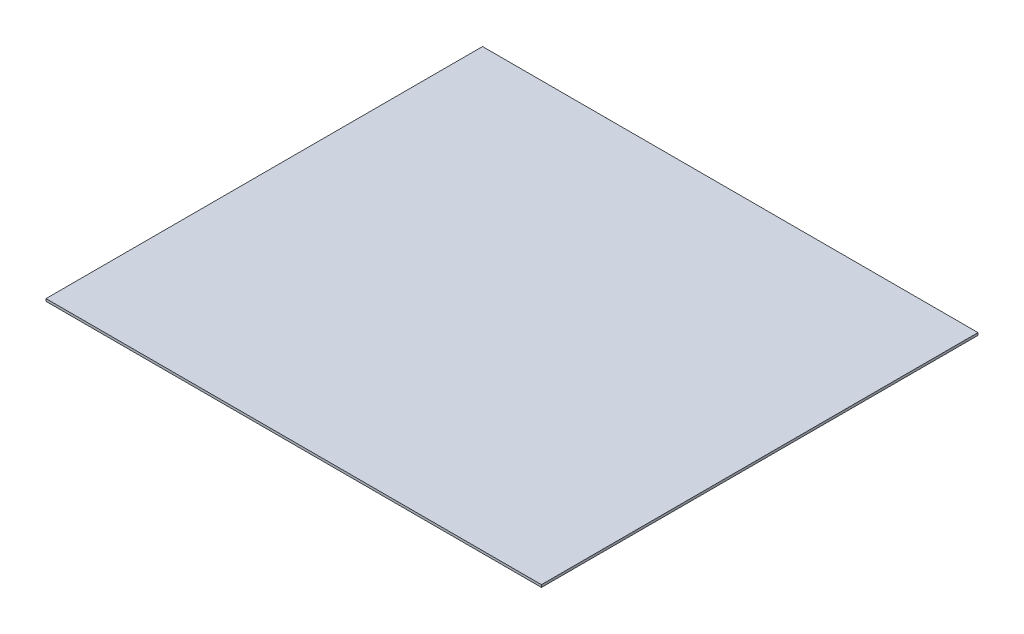
from build123d import *

# Parameters (mm, degrees)
SKETCH1_W           = 2565.4
SKETCH1_H           = 2260.346
BOSS_EXTRUDE1_DEPTH = 12.7


with BuildPart() as part:
    # Sketch1 → Boss-Extrude1 (new body)
    with BuildSketch(Plane(origin=(0, 0, 0), x_dir=(1, 0, 0), z_dir=(0, 1, 0))):
        Rectangle(SKETCH1_W, SKETCH1_H)
    extrude(amount=BOSS_EXTRUDE1_DEPTH)


solid = part.part
